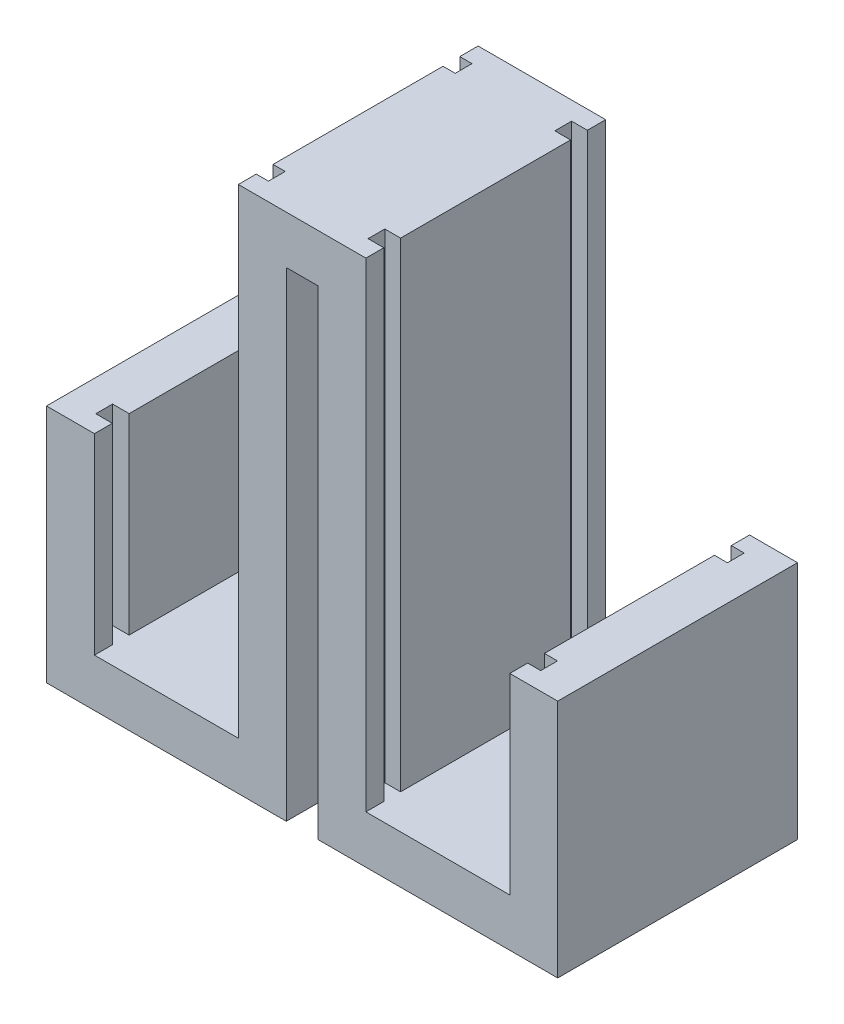
from build123d import *

# Parameters (mm, degrees)
EXTRU_MINCE1_DEPTH      = 50
ESQUISSE2_W             = 36
ESQUISSE2_H             = 3.5
ENL_V_MAT_EXTRU_1_DEPTH = 100


with BuildPart() as part:
    # Esquisse1 → Extru.-Mince1 (new body)
    with BuildSketch(Plane.XY):
        Polygon((-50, 50), (-50, 0), (0, 0), (0, 100), (6.6, 100), (6.6, 0), (56.6, 0), (56.6, 50), (46.6, 50), (46.6, 10), (16.6, 10), (16.6, 110), (-10, 110), (-10, 10), (-40, 10), (-40, 50), align=None)
    extrude(amount=EXTRU_MINCE1_DEPTH)

    # Esquisse2 → Enlèv. mat.-Extru.1 (cut)
    with BuildSketch(Plane(origin=(0, 10, 0), x_dir=(1, 0, 0), z_dir=(0, 1, 0))):
        with Locations((-25.454999668, -5.571109307)):
            Rectangle(ESQUISSE2_W, ESQUISSE2_H)
        with Locations((-25.454999668, -44.515273736)):
            Rectangle(ESQUISSE2_W, ESQUISSE2_H)
        with Locations((31.312560908, -5.571109307)):
            Rectangle(ESQUISSE2_W, ESQUISSE2_H)
        with Locations((31.312560908, -44.515273736)):
            Rectangle(ESQUISSE2_W, ESQUISSE2_H)
    extrude(amount=ENL_V_MAT_EXTRU_1_DEPTH, mode=Mode.SUBTRACT)


solid = part.part
